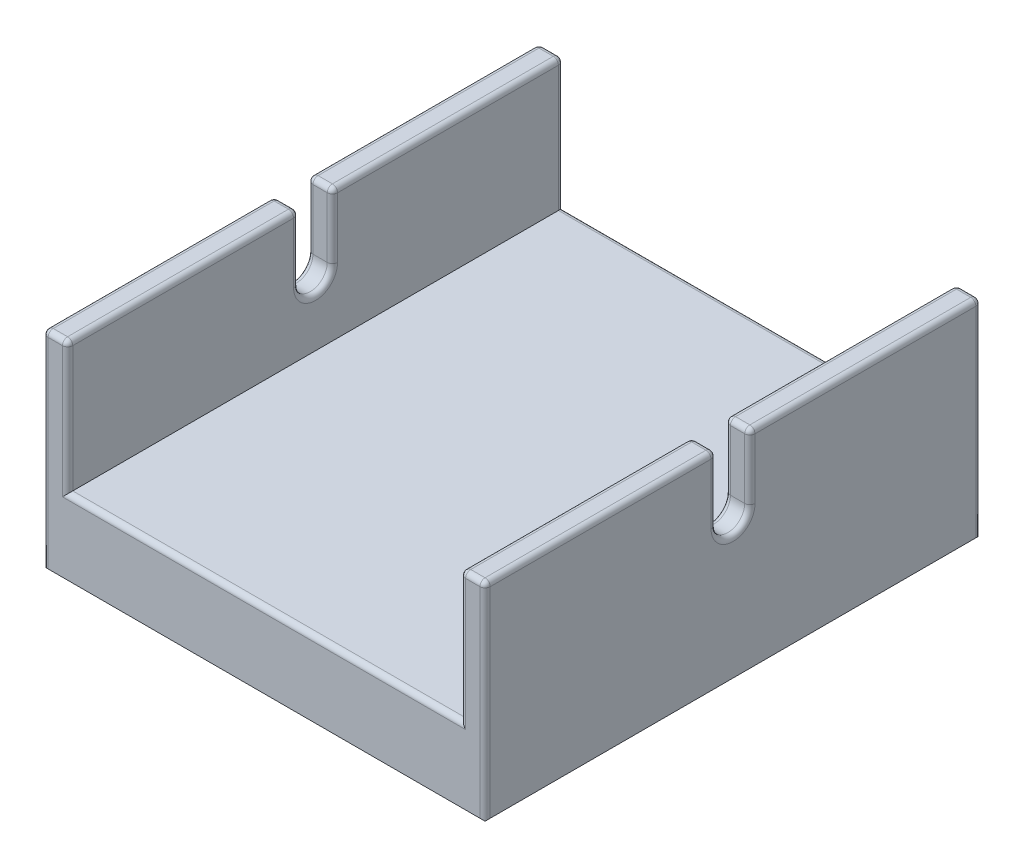
from build123d import *

# Parameters (mm, degrees)
SKETCH2_W           = 85.7504
SKETCH2_H           = 96.2
BOSS_EXTRUDE1_DEPTH = 15
SKETCH2_3_W         = 4.7752
SKETCH2_3_H         = 96.2
BOSS_EXTRUDE2_DEPTH = 25.4
CUT_EXTRUDE1_DEPTH  = 142.901131427
CHAMFER1_SIZE       = 0.5
FILLET2_R           = 1


with BuildPart() as part:
    # Sketch2 → Boss-Extrude1 (new body)
    with BuildSketch(Plane(origin=(0, 34, 0), x_dir=(-1, 0, 0), z_dir=(0, -1, 0))):
        with Locations((-150, -48.1)):
            Rectangle(SKETCH2_W, SKETCH2_H)
    extrude(amount=BOSS_EXTRUDE1_DEPTH)

    # Sketch2_3 → Boss-Extrude2 (add)
    with BuildSketch(Plane(origin=(0, 34, 0), x_dir=(-1, 0, 0), z_dir=(0, -1, 0))):
        with Locations((-109.5124, -48.1)):
            Rectangle(SKETCH2_3_W, SKETCH2_3_H)
        with Locations((-190.4876, -48.1)):
            Rectangle(SKETCH2_3_W, SKETCH2_3_H)
    extrude(amount=-BOSS_EXTRUDE2_DEPTH)

    # Sketch3 → Cut-Extrude1 (cut, through all)
    with BuildSketch(Plane(origin=(192.8752, 0, 0), x_dir=(0, 0, -1), z_dir=(1, 0, 0))):
        with BuildLine():
            Line((-51.3639, 46.7), (-51.3639, 59.4))
            Line((-51.3639, 59.4), (-44.8361, 59.4))
            Line((-44.8361, 59.4), (-44.8361, 46.7))
            ThreePointArc((-44.8361, 46.7), (-48.1, 43.4361), (-51.3639, 46.7))
        make_face()
    extrude(amount=-CUT_EXTRUDE1_DEPTH, mode=Mode.SUBTRACT)

    # Chamfer1
    chamfer1_edges = [part.edges().sort_by_distance(p)[0] for p in [
        (150, 19, 96.2),
        (192.8752, 19, 48.1),
        (150, 19, 0),
        (107.1248, 19, 48.1),
    ]]
    chamfer(chamfer1_edges, length=CHAMFER1_SIZE)

    # Fillet2
    fillet2_edges = [part.edges().sort_by_distance(p)[0] for p in [
        (111.9, 53.05, 44.8361),
        (111.9, 43.4361, 48.1),
        (107.1248, 53.05, 44.8361),
        (107.1248, 43.4361, 48.1),
        (192.8752, 53.05, 44.8361),
        (192.8752, 43.4361, 48.1),
        (188.1, 53.05, 44.8361),
        (188.1, 43.4361, 48.1),
        (109.5124, 59.4, 0),
        (111.9, 59.4, 22.41805),
        (109.5124, 59.4, 44.8361),
        (107.1248, 59.4, 22.41805),
        (109.5124, 59.4, 96.2),
        (107.1248, 59.4, 73.78195),
        (111.9, 59.4, 73.78195),
        (190.4876, 59.4, 0),
        (192.8752, 59.4, 22.41805),
        (190.4876, 59.4, 44.8361),
        (188.1, 59.4, 22.41805),
        (190.4876, 59.4, 96.2),
        (188.1, 59.4, 73.78195),
        (192.8752, 59.4, 73.78195),
        (111.9, 53.05, 51.3639),
        (109.5124, 59.4, 51.3639),
        (107.1248, 53.05, 51.3639),
        (192.8752, 53.05, 51.3639),
        (190.4876, 59.4, 51.3639),
        (188.1, 53.05, 51.3639),
        (150, 34, 96.2),
        (107.1248, 39.45, 96.2),
        (188.1, 46.7, 96.2),
        (111.9, 46.7, 96.2),
        (192.8752, 39.45, 96.2),
        (107.1248, 39.45, 0),
        (192.8752, 39.45, 0),
        (188.1, 46.7, 0),
        (150, 34, 0),
        (111.9, 46.7, 0),
    ]]
    fillet(fillet2_edges, radius=FILLET2_R)


solid = part.part
